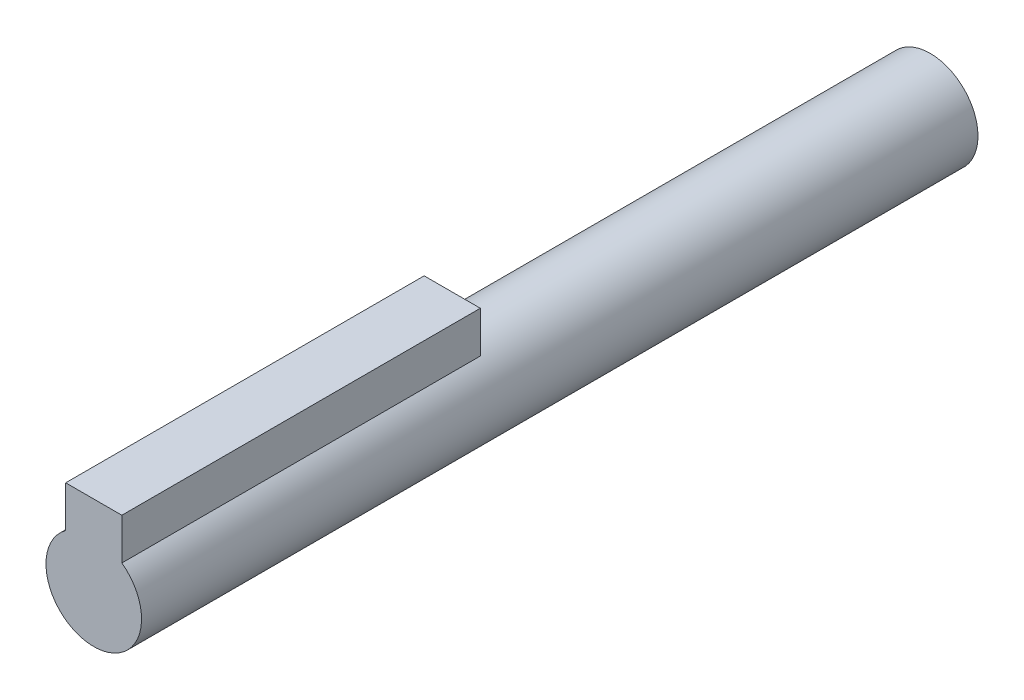
from build123d import *

# Parameters (mm, degrees)
SKETCH1_R           = 4
BOSS_EXTRUDE1_DEPTH = 70
SKETCH2_W           = 4.7
SKETCH2_H           = 5.4
BOSS_EXTRUDE4_DEPTH = 30


with BuildPart() as part:
    # Sketch1 → Boss-Extrude1 (new body)
    with BuildSketch(Plane.XY):
        Circle(SKETCH1_R)
    extrude(amount=BOSS_EXTRUDE1_DEPTH)

    # Sketch2 → Boss-Extrude4 (add)
    with BuildSketch(Plane.XY.offset(70)):
        with Locations((0, 4)):
            Rectangle(SKETCH2_W, SKETCH2_H)
    extrude(amount=-BOSS_EXTRUDE4_DEPTH)


solid = part.part
